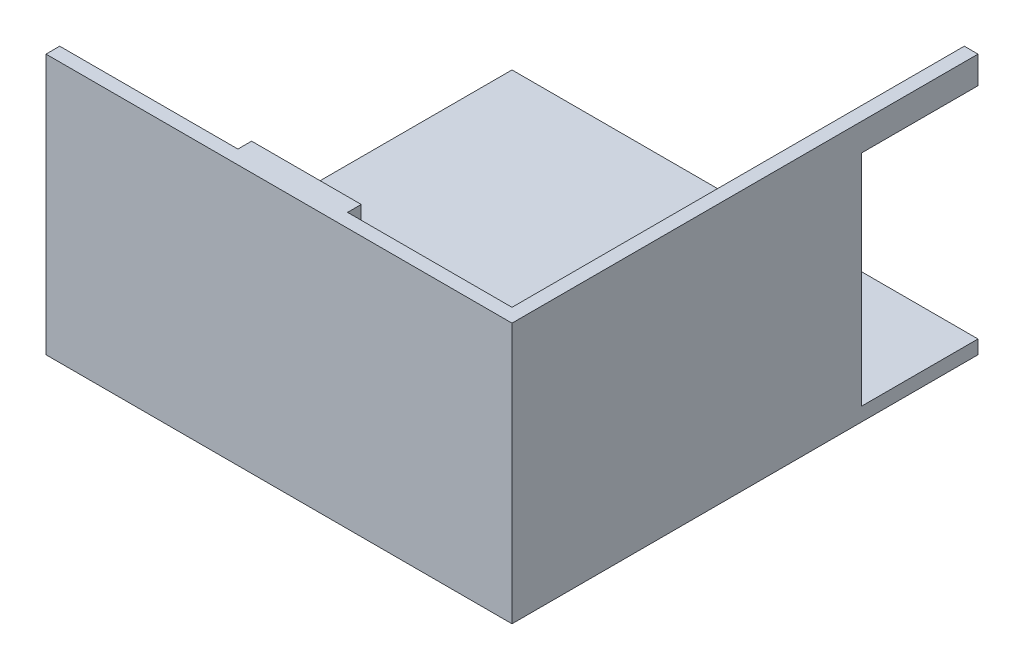
from build123d import *

# Parameters (mm, degrees)
SKETCH1_W           = 431.8
SKETCH1_H           = 431.8
SKETCH1_W_2         = 406.4
SKETCH1_H_2         = 406.4
EXTRUDE_THIN1_DEPTH = 228.6
SKETCH2_W           = 431.8
SKETCH2_H           = 431.8
EXTRUDE1_DEPTH      = 12.7
CUT_EXTRUDE1_DEPTH  = 229.6
EXTRUDE2_DEPTH      = 228.6
SKETCH5_W           = 12.7
SKETCH5_H           = 107.95
CUT_EXTRUDE2_DEPTH  = 203.2


with BuildPart() as part:
    # Sketch1 → Extrude-Thin1 (new body)
    with BuildSketch(Plane(origin=(0, 0, 0), x_dir=(1, 0, 0), z_dir=(0, 1, 0))):
        with Locations((153.377464009, 155.501162791)):
            Rectangle(SKETCH1_W, SKETCH1_H)
        with Locations((153.377464009, 155.501162791)):
            Rectangle(SKETCH1_W_2, SKETCH1_H_2, mode=Mode.SUBTRACT)
    extrude(amount=EXTRUDE_THIN1_DEPTH)

    # Sketch2 → Extrude1 (add)
    with BuildSketch(Plane.XZ):
        with Locations((153.377464009, -155.501162791)):
            Rectangle(SKETCH2_W, SKETCH2_H)
    extrude(amount=EXTRUDE1_DEPTH)

    # Sketch3 → Cut-Extrude1 (cut, through all)
    with BuildSketch(Plane(origin=(0, 0, 0), x_dir=(-1, 0, 0), z_dir=(0, 1, 0))):
        Polygon((-356.577464009, -371.401162791), (62.522535991, -371.401162791), (62.522535991, 47.698837209), (49.822535991, 47.698837209), (49.822535991, -358.701162791), (-356.577464009, -358.701162791), align=None)
    extrude(amount=CUT_EXTRUDE1_DEPTH, mode=Mode.SUBTRACT)

    # Sketch4 → Extrude2 (add)
    with BuildSketch(Plane(origin=(0, 0, 0), x_dir=(-1, 0, 0), z_dir=(0, 1, 0))):
        Polygon((-153.377464009, 60.398837209), (-204.177464009, 60.398837209), (-204.177464009, 34.998837209), (-153.377464009, 34.998837209), (-102.577464009, 34.998837209), (-102.577464009, 60.398837209), align=None)
    extrude(amount=EXTRUDE2_DEPTH)

    # Sketch5 → Cut-Extrude2 (cut)
    with BuildSketch(Plane(origin=(0, 0, 0), x_dir=(-1, 0, 0), z_dir=(0, 1, 0))):
        with Locations((-362.927464009, -317.426162791)):
            Rectangle(SKETCH5_W, SKETCH5_H)
    extrude(amount=CUT_EXTRUDE2_DEPTH, mode=Mode.SUBTRACT)


solid = part.part
